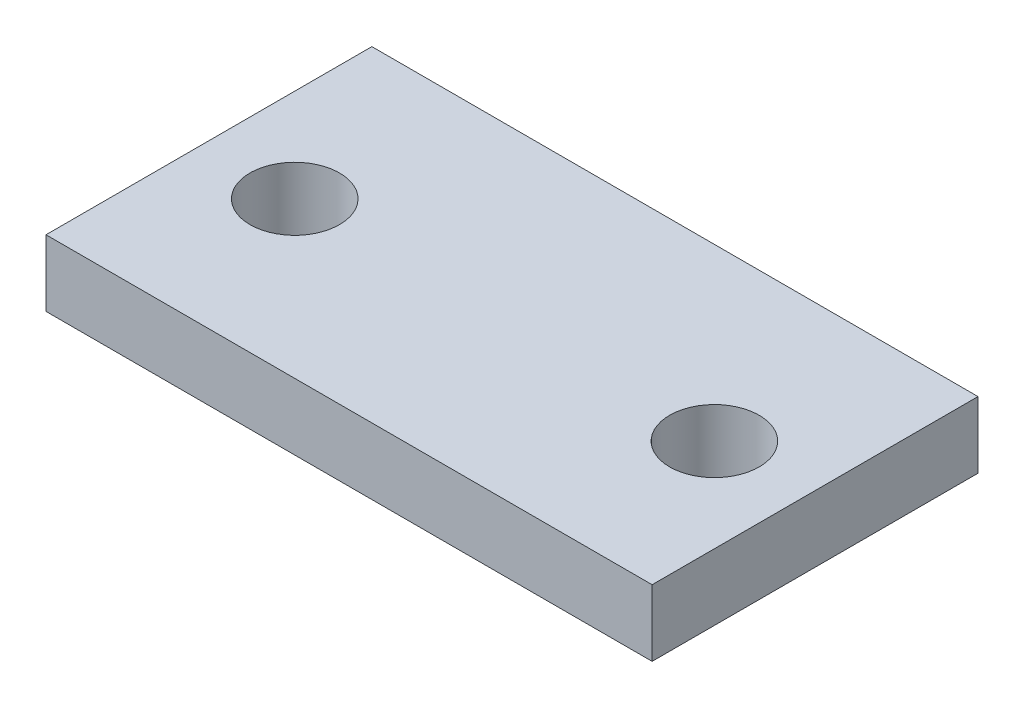
from build123d import *

# Parameters (mm, degrees)
SKETCH1_W           = 91.267371632
SKETCH1_H           = 49.068479372
BOSS_EXTRUDE1_DEPTH = 10
SKETCH2_R           = 6.742418782
CUT_EXTRUDE2_DEPTH  = 10


with BuildPart() as part:
    # Sketch1 → Boss-Extrude1 (new body)
    with BuildSketch(Plane(origin=(0, 0, 0), x_dir=(1, 0, 0), z_dir=(0, 1, 0))):
        with Locations((-64.279707977, 31.526497996)):
            Rectangle(SKETCH1_W, SKETCH1_H)
    extrude(amount=BOSS_EXTRUDE1_DEPTH)

    # Sketch2 → Cut-Extrude2 (cut)
    with BuildSketch(Plane(origin=(0, 10, 0), x_dir=(1, 0, 0), z_dir=(0, 1, 0))):
        with Locations((-95.875303576, 30.408499998)):
            Circle(SKETCH2_R)
    cut_extrude2 = extrude(amount=-CUT_EXTRUDE2_DEPTH, mode=Mode.SUBTRACT)

    # Mirror1: Cut-Extrude2 across plane
    add(cut_extrude2.mirror(Plane.ZY.offset(64.279707977)), mode=Mode.SUBTRACT)


solid = part.part
